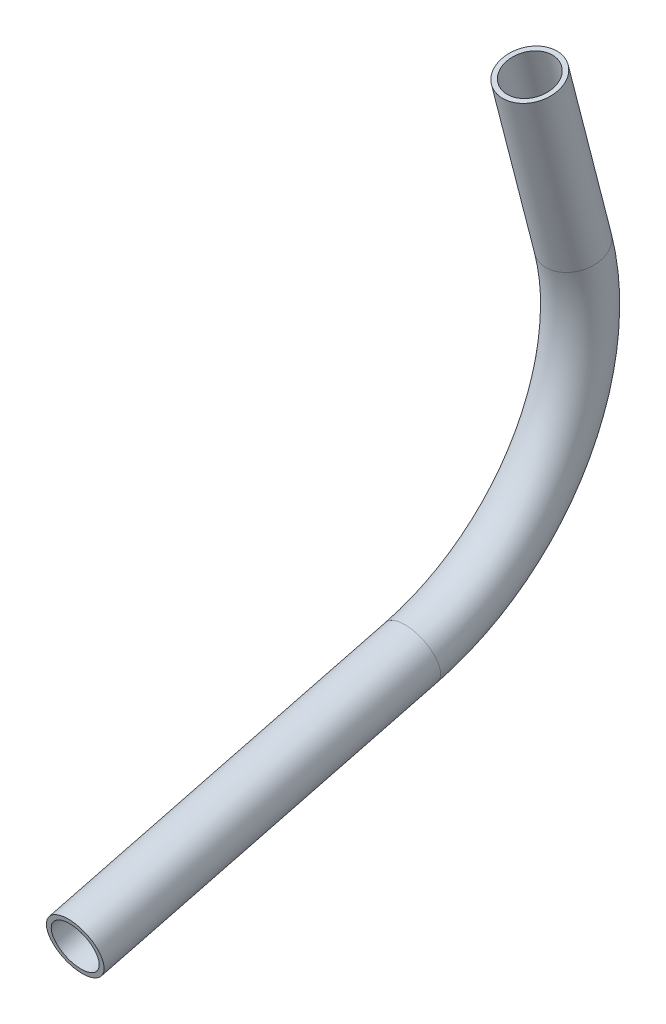
from build123d import *

# Parameters (mm, degrees)
SKETCH11_R                = 6.35
SKETCH11_R_2              = 5.2832
PIPE_0_5_SCH_40_1_DEPTH   = 78.793048101
SKETCH11_ON_SEGMENT_2_R   = 6.35
SKETCH11_ON_SEGMENT_2_R_2 = 5.2832
PIPE_0_5_SCH_40_1_2_ANGLE = 90
SKETCH11_ON_SEGMENT_3_R   = 6.35
SKETCH11_ON_SEGMENT_3_R_2 = 5.2832
PIPE_0_5_SCH_40_1_3_DEPTH = 39.340431637


with BuildPart() as part:
    # Sketch11 → Pipe 0.5 SCH 40(1) (new body)
    with BuildSketch(Plane(origin=(0, 633.468785437, 190.922921196), x_dir=(0, 0.9684692926437414, 0.2491329548777745), z_dir=(0, 0.2491329548777745, -0.9684692926437414))):
        Circle(SKETCH11_R)
        Circle(SKETCH11_R_2, mode=Mode.SUBTRACT)
    extrude(amount=PIPE_0_5_SCH_40_1_DEPTH)


with BuildPart() as body_2:
    # Sketch11 on segment 2 (carried to the start of arc 2) → Pipe 0.5 SCH 40_1 2 (revolve)
    with BuildSketch(Plane(origin=(0, 653.098730334, 114.614273636), x_dir=(0, 0.968469293, 0.249132955), z_dir=(0, 0.249132955, -0.968469293))):
        Circle(SKETCH11_ON_SEGMENT_2_R)
        Circle(SKETCH11_ON_SEGMENT_2_R_2, mode=Mode.SUBTRACT)
    revolve(axis=Axis((0, 702.296970401, 127.270227744), (1, 0, 0)), revolution_arc=PIPE_0_5_SCH_40_1_2_ANGLE)


with BuildPart() as body_3:
    # Sketch11 on segment 3 (carried to segment 3) → Pipe 0.5 SCH 40_1 3 (new body)
    with BuildSketch(Plane(origin=(0, 714.952924509, 78.071987677), x_dir=(0, -0.249132955, 0.968469293), z_dir=(0, 0.968469293, 0.249132955))):
        Circle(SKETCH11_ON_SEGMENT_3_R)
        Circle(SKETCH11_ON_SEGMENT_3_R_2, mode=Mode.SUBTRACT)
    extrude(amount=PIPE_0_5_SCH_40_1_3_DEPTH)


solid = Compound([part.part, body_2.part, body_3.part])
